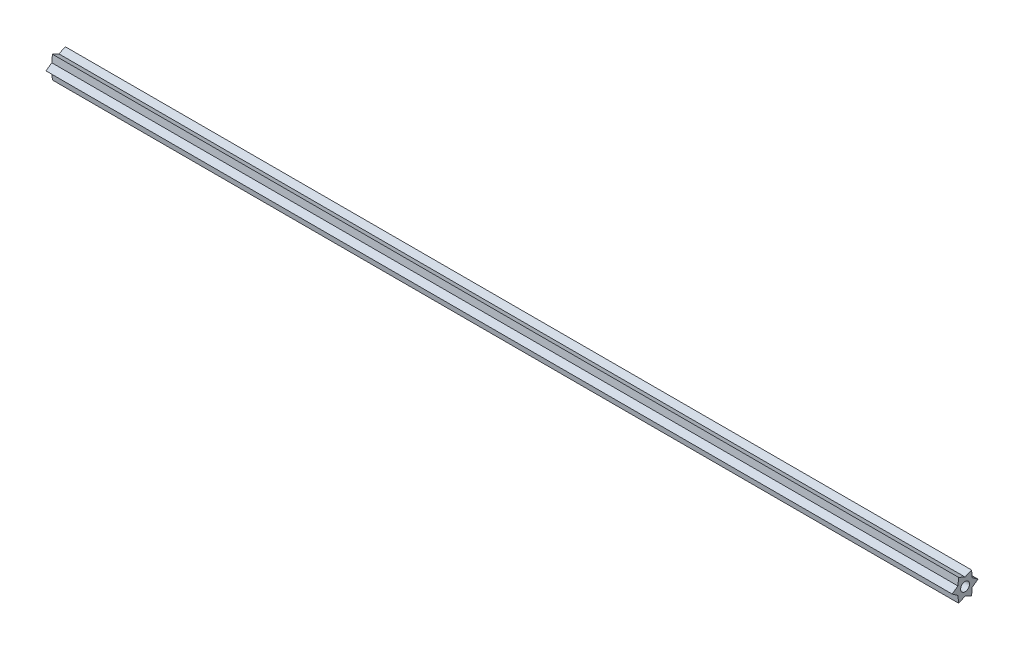
from build123d import *

# Parameters (mm, degrees)
BOSS_EXTRUDE1_DEPTH = 514.35
CUT_EXTRUDE1_REACH  = 516.35
SKETCH2_R           = 2.54


with BuildPart() as part:
    # Sketch1 → Boss-Extrude1 (new body)
    with BuildSketch(Plane(origin=(0, 0, 0), x_dir=(0, 0, -1), z_dir=(1, 0, 0))):
        Polygon((-3.666174209, 6.35), (0, 4.699060448), (3.666174209, 6.35), (4.069505722, 2.349530224), (7.332348419, 0), (4.069505722, -2.349530224), (3.666174209, -6.35), (0, -4.699060448), (-3.666174209, -6.35), (-4.069505722, -2.349530224), (-7.332348419, 0), (-4.069505722, 2.349530224), align=None)
    extrude(amount=BOSS_EXTRUDE1_DEPTH)

    # Sketch2 → Cut-Extrude1 (cut, up to next)
    with BuildSketch(Plane(origin=(514.35, 0, 0), x_dir=(0, 0, -1), z_dir=(1, 0, 0)), mode=Mode.PRIVATE) as cut_extrude1_sk1:
        Circle(SKETCH2_R)
    cut_extrude1_tool1 = extrude(cut_extrude1_sk1.sketch, amount=-CUT_EXTRUDE1_REACH, mode=Mode.PRIVATE) & part.part
    add(cut_extrude1_tool1.solids().sort_by_distance((514.35, 0, 0))[0], mode=Mode.SUBTRACT)


solid = part.part
